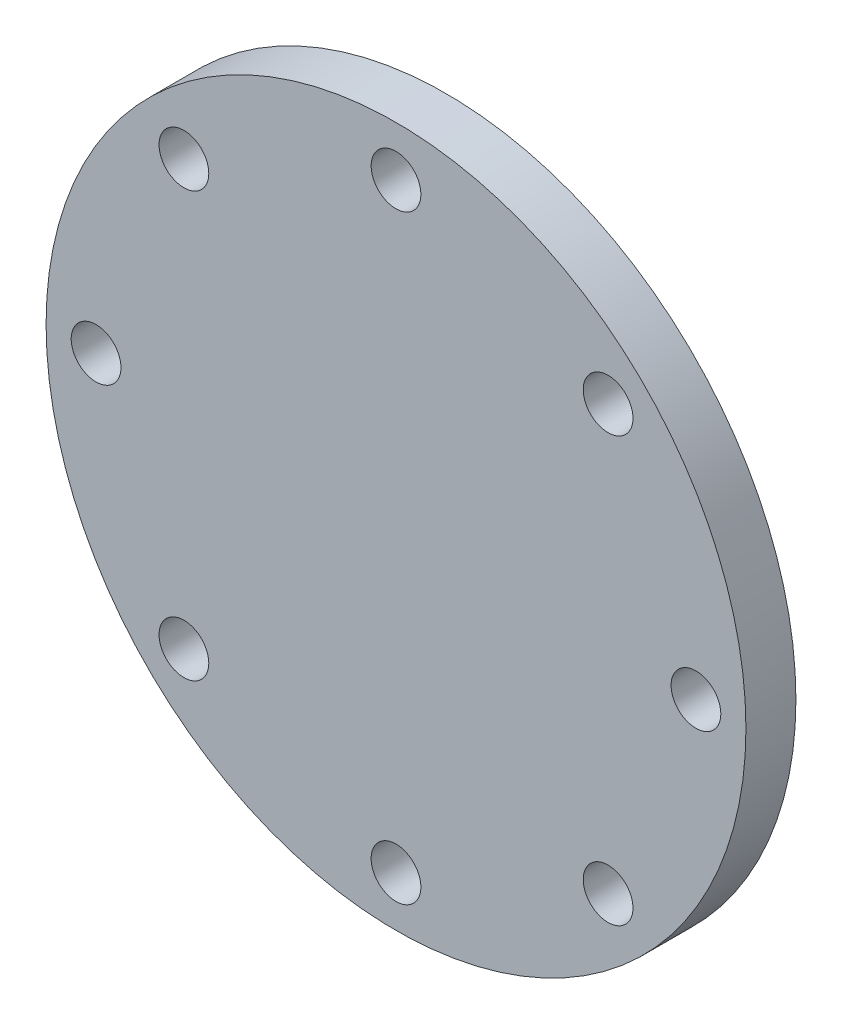
from build123d import *

# Parameters (mm, degrees)
SKETCH1_R         = 17.78
EXTRUDE1_DEPTH    = 2.54
CIRPATTERN2_COUNT = 8
SKETCH7_R         = 3.175
EXTRUDE2_DEPTH    = 2.54


with BuildPart() as part:
    # Sketch1 → Extrude1 (new body)
    with BuildSketch(Plane.XY):
        Circle(SKETCH1_R)
    extrude(amount=EXTRUDE1_DEPTH)

    # Sketch6 → #39 (0.0995) Diameter Hole2 (revolve, cut)
    with BuildSketch(Plane(origin=(0, 15.24, 2.54), x_dir=(0, -1, 0), z_dir=(1, 0, 0))):
        Polygon((0, 0), (0, 10.919277521), (1.26365, 10.16), (1.26365, 0), align=None)
    f_39_0_0995_diameter_hole2 = revolve(axis=Axis((0, 15.24, 8.89), (0, 0, -1)), mode=Mode.SUBTRACT)

    # CirPattern2: #39 (0.0995) Diameter Hole2 ×8 about axis
    cirpattern2_axis = Axis((0, 0, 0), (0, 0, 1))
    for i in range(1, CIRPATTERN2_COUNT):
        add(f_39_0_0995_diameter_hole2.rotate(cirpattern2_axis, i * 360 / CIRPATTERN2_COUNT), mode=Mode.SUBTRACT)

    # Sketch7 → Extrude2 (add)
    with BuildSketch(Plane(origin=(0, 0, 0), x_dir=(-1, 0, 0), z_dir=(0, 0, -1))):
        Circle(SKETCH7_R)
    extrude(amount=EXTRUDE2_DEPTH)


solid = part.part
